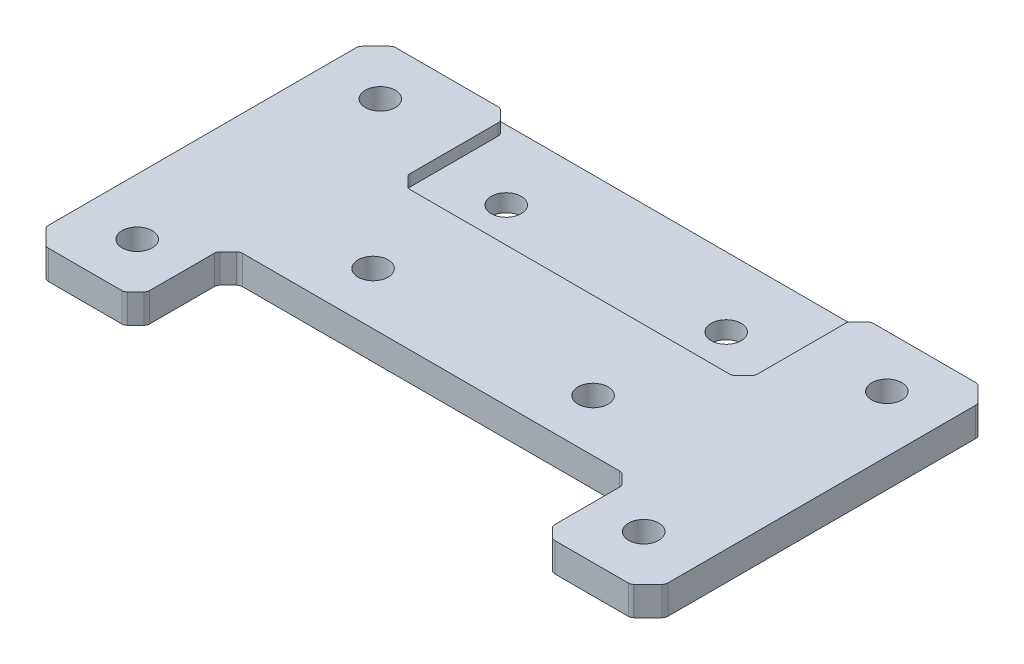
from build123d import *

# Parameters (mm, degrees)
SKETCH1_W                   = 107
SKETCH1_H                   = 60
BOSS_EXTRUDE1_DEPTH         = 5
SKETCH2_W                   = 60
SKETCH2_H                   = 20
CUT_EXTRUDE1_DEPTH          = 2
CUT_EXTRUDE2_REACH          = 7
SKETCH3_W                   = 70
SKETCH3_H                   = 16
CHAMFER1_SIZE               = 2
CHAMFER2_SIZE               = 3
FILLET1_R                   = 1
TAP_DRILL_FOR_M5_TAP1_D     = 5.2
TAP_DRILL_FOR_M5_TAP1_DEPTH = 46
TAP_DRILL_FOR_M5_TAP1_TIP   = 1.562237609
TAP_DRILL_FOR_M5_TAP2_D     = 5.2
TAP_DRILL_FOR_M5_TAP2_DEPTH = 46
TAP_DRILL_FOR_M5_TAP2_TIP   = 1.562237609


with BuildPart() as part:
    # Sketch1 → Boss-Extrude1 (new body)
    with BuildSketch(Plane(origin=(0, 0, 0), x_dir=(1, 0, 0), z_dir=(0, 1, 0))):
        Rectangle(SKETCH1_W, SKETCH1_H)
    extrude(amount=BOSS_EXTRUDE1_DEPTH)

    # Sketch2 → Cut-Extrude1 (cut)
    with BuildSketch(Plane(origin=(0, 5, 0), x_dir=(1, 0, 0), z_dir=(0, 1, 0))):
        with Locations((0, 20)):
            Rectangle(SKETCH2_W, SKETCH2_H)
    extrude(amount=-CUT_EXTRUDE1_DEPTH, mode=Mode.SUBTRACT)

    # Sketch3 → Cut-Extrude2 (cut, up to next)
    with BuildSketch(Plane(origin=(0, 5, 0), x_dir=(1, 0, 0), z_dir=(0, 1, 0)), mode=Mode.PRIVATE) as cut_extrude2_sk1:
        with Locations((0, -22)):
            Rectangle(SKETCH3_W, SKETCH3_H)
    cut_extrude2_tool1 = extrude(cut_extrude2_sk1.sketch, amount=-CUT_EXTRUDE2_REACH, mode=Mode.PRIVATE) & part.part
    add(cut_extrude2_tool1.solids().sort_by_distance((0, 5, 22))[0], mode=Mode.SUBTRACT)

    # Chamfer1
    chamfer1_edges = [part.edges().sort_by_distance(p)[0] for p in [
        (-30, 4, -10),
        (-30, 4, -30),
        (30, 4, -30),
        (30, 4, -10),
        (35, 2.5, 14),
        (35, 2.5, 30),
        (-35, 2.5, 30),
        (-35, 2.5, 14),
    ]]
    chamfer(chamfer1_edges, length=CHAMFER1_SIZE)

    # Chamfer2
    chamfer2_edges = [part.edges().sort_by_distance(p)[0] for p in [
        (53.5, 2.5, 30),
        (-53.5, 2.5, 30),
        (-53.5, 2.5, -30),
        (53.5, 2.5, -30),
    ]]
    chamfer(chamfer2_edges, length=CHAMFER2_SIZE)

    # Fillet1
    fillet1_edges = [part.edges().sort_by_distance(p)[0] for p in [
        (53.5, 2.5, -27),
        (53.5, 2.5, 27),
        (50.5, 2.5, 30),
        (-50.5, 2.5, -30),
        (50.5, 2.5, -30),
        (-53.5, 2.5, 27),
        (-53.5, 2.5, -27),
        (-50.5, 2.5, 30),
        (-32, 4, -30),
        (32, 4, -30),
        (30, 4, -12),
        (30, 4, -28),
        (-28, 4, -10),
        (28, 4, -10),
        (-30, 4, -28),
        (-30, 4, -12),
        (35, 2.5, 16),
        (35, 2.5, 28),
        (37, 2.5, 30),
        (-33, 2.5, 14),
        (33, 2.5, 14),
        (-35, 2.5, 28),
        (-35, 2.5, 16),
        (-37, 2.5, 30),
    ]]
    fillet(fillet1_edges, radius=FILLET1_R)

    # Tap Drill for M5 Tap1
    with Locations(Plane(origin=(-43.75, 5, -21), x_dir=(0, 0, 1), z_dir=(0, 1, 0))):
        with Locations((0, 0), (42, 0), (26, 24.75), (26, 62.75), (0, 87.5), (42, 87.5)):
            Hole(TAP_DRILL_FOR_M5_TAP1_D / 2, depth=TAP_DRILL_FOR_M5_TAP1_DEPTH)
            with Locations((0, 0, -(TAP_DRILL_FOR_M5_TAP1_DEPTH + TAP_DRILL_FOR_M5_TAP1_TIP / 2))):  # 118° drill point
                Cone(0, TAP_DRILL_FOR_M5_TAP1_D / 2, TAP_DRILL_FOR_M5_TAP1_TIP, mode=Mode.SUBTRACT)

    # Tap Drill for M5 Tap2
    with Locations(Plane(origin=(-19, 3, -18), x_dir=(0, 0, 1), z_dir=(0, 1, 0))):
        with Locations((0, 0), (0, 38)):
            Hole(TAP_DRILL_FOR_M5_TAP2_D / 2, depth=TAP_DRILL_FOR_M5_TAP2_DEPTH)
            with Locations((0, 0, -(TAP_DRILL_FOR_M5_TAP2_DEPTH + TAP_DRILL_FOR_M5_TAP2_TIP / 2))):  # 118° drill point
                Cone(0, TAP_DRILL_FOR_M5_TAP2_D / 2, TAP_DRILL_FOR_M5_TAP2_TIP, mode=Mode.SUBTRACT)


solid = part.part
